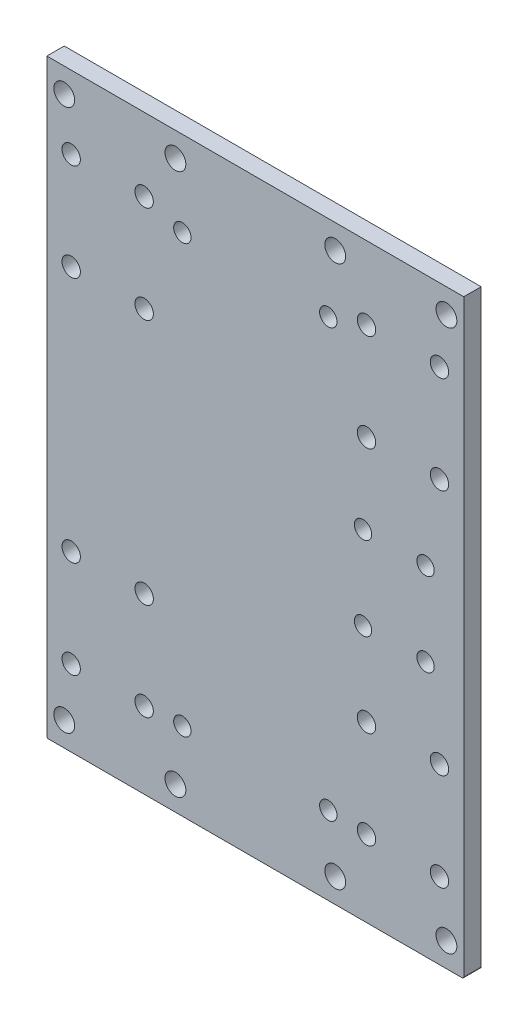
from build123d import *

# Parameters (mm, degrees)
SKETCH1_W           = 120
SKETCH1_H           = 170
SKETCH1_R           = 2.65
SKETCH1_R_2         = 2.5
SKETCH1_R_3         = 3
BOSS_EXTRUDE1_DEPTH = 5
FILLET1_R           = 0.5


with BuildPart() as part:
    # Sketch1 → Boss-Extrude1 (new body)
    with BuildSketch(Plane.XY):
        with Locations((60, 85)):
            Rectangle(SKETCH1_W, SKETCH1_H)
        with Locations((28, 22)):
            Circle(SKETCH1_R, mode=Mode.SUBTRACT)
        with Locations((7, 22)):
            Circle(SKETCH1_R, mode=Mode.SUBTRACT)
        with Locations((7, 50)):
            Circle(SKETCH1_R, mode=Mode.SUBTRACT)
        with Locations((28, 50)):
            Circle(SKETCH1_R, mode=Mode.SUBTRACT)
        with Locations((28, 121)):
            Circle(SKETCH1_R, mode=Mode.SUBTRACT)
        with Locations((7, 121)):
            Circle(SKETCH1_R, mode=Mode.SUBTRACT)
        with Locations((28, 149)):
            Circle(SKETCH1_R, mode=Mode.SUBTRACT)
        with Locations((7, 149)):
            Circle(SKETCH1_R, mode=Mode.SUBTRACT)
        with Locations((39, 22.5)):
            Circle(SKETCH1_R_2, mode=Mode.SUBTRACT)
        with Locations((81, 22.5)):
            Circle(SKETCH1_R_2, mode=Mode.SUBTRACT)
        with Locations((5, 163)):
            Circle(SKETCH1_R_3, mode=Mode.SUBTRACT)
        with Locations((115, 163)):
            Circle(SKETCH1_R_3, mode=Mode.SUBTRACT)
        with Locations((37, 163)):
            Circle(SKETCH1_R_3, mode=Mode.SUBTRACT)
        with Locations((83, 163)):
            Circle(SKETCH1_R_3, mode=Mode.SUBTRACT)
        with Locations((115, 7)):
            Circle(SKETCH1_R_3, mode=Mode.SUBTRACT)
        with Locations((83, 7)):
            Circle(SKETCH1_R_3, mode=Mode.SUBTRACT)
        with Locations((37, 7)):
            Circle(SKETCH1_R_3, mode=Mode.SUBTRACT)
        with Locations((5, 7)):
            Circle(SKETCH1_R_3, mode=Mode.SUBTRACT)
        with Locations((39, 145.5)):
            Circle(SKETCH1_R_2, mode=Mode.SUBTRACT)
        with Locations((81, 145.5)):
            Circle(SKETCH1_R_2, mode=Mode.SUBTRACT)
        with Locations((113, 149)):
            Circle(SKETCH1_R, mode=Mode.SUBTRACT)
        with Locations((92, 149)):
            Circle(SKETCH1_R, mode=Mode.SUBTRACT)
        with Locations((92, 121)):
            Circle(SKETCH1_R, mode=Mode.SUBTRACT)
        with Locations((113, 121)):
            Circle(SKETCH1_R, mode=Mode.SUBTRACT)
        with Locations((92, 50)):
            Circle(SKETCH1_R, mode=Mode.SUBTRACT)
        with Locations((113, 50)):
            Circle(SKETCH1_R, mode=Mode.SUBTRACT)
        with Locations((113, 22)):
            Circle(SKETCH1_R, mode=Mode.SUBTRACT)
        with Locations((92, 22)):
            Circle(SKETCH1_R, mode=Mode.SUBTRACT)
        with Locations((109, 97.5)):
            Circle(SKETCH1_R_2, mode=Mode.SUBTRACT)
        with Locations((109, 73.5)):
            Circle(SKETCH1_R_2, mode=Mode.SUBTRACT)
        with Locations((91, 73.5)):
            Circle(SKETCH1_R_2, mode=Mode.SUBTRACT)
        with Locations((91, 97.5)):
            Circle(SKETCH1_R_2, mode=Mode.SUBTRACT)
    extrude(amount=BOSS_EXTRUDE1_DEPTH)

    # Fillet1
    fillet1_edges = [part.edges().sort_by_distance(p)[0] for p in [
        (120, 0, 2.5),
        (0, 0, 2.5),
    ]]
    fillet(fillet1_edges, radius=FILLET1_R)


solid = part.part
